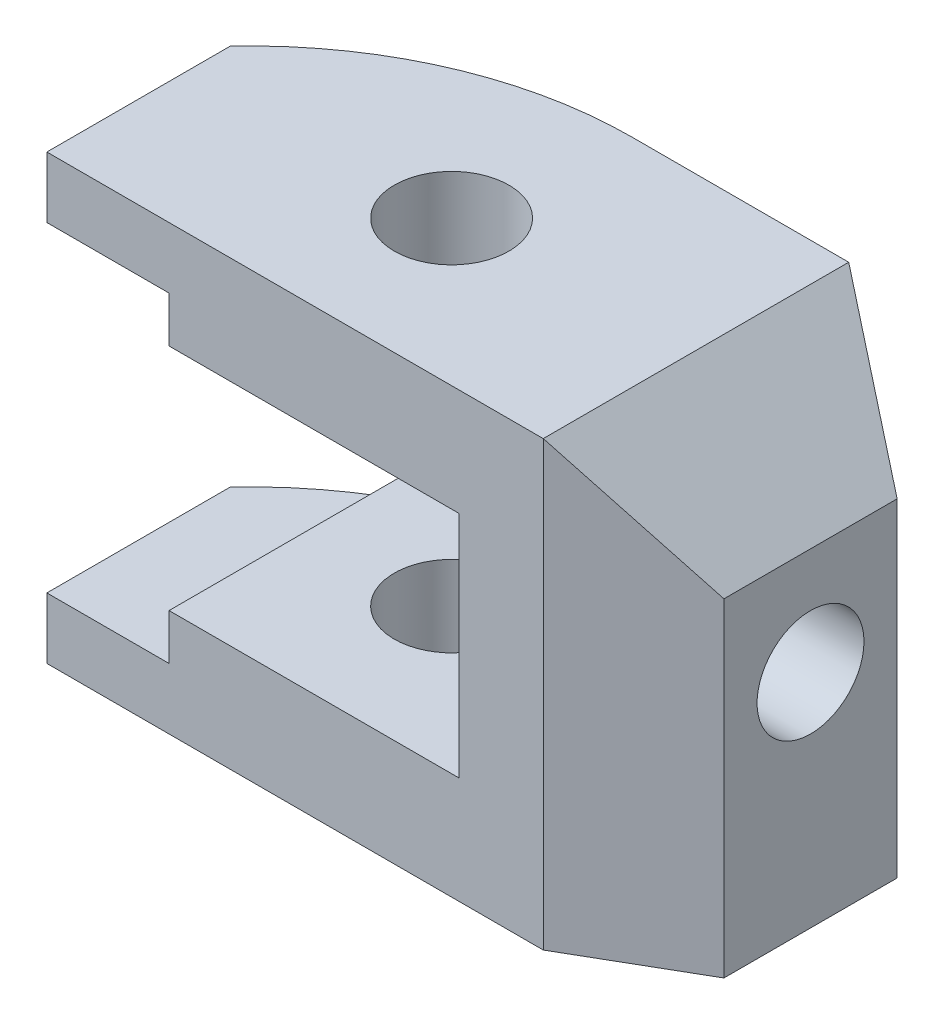
from build123d import *

# Parameters (mm, degrees)
SKETCH1_R           = 7.5
BOSS_EXTRUDE1_DEPTH = 58
CUT_EXTRUDE1_DEPTH  = 58
CUT_EXTRUDE2_DEPTH  = 58
CUT_EXTRUDE3_REACH  = 82
SKETCH4_R           = 7


with BuildPart() as part:
    # Sketch1 → Boss-Extrude1 (new body)
    with BuildSketch(Plane(origin=(0, 0, 0), x_dir=(1, 0, 0), z_dir=(0, 1, 0))):
        with BuildLine():
            Line((36.66060556, 40), (65, 40))
            Line((65, 40), (80, 31.339745962))
            Line((80, 31.339745962), (80, 8.660254038))
            Line((80, 8.660254038), (65, 0))
            Line((65, 0), (0, 0))
            Line((0, 0), (0, 24))
            ThreePointArc((0, 24), (16.66060556, 35.82575695), (36.66060556, 40))
        make_face()
        with Locations((34, 19)):
            Circle(SKETCH1_R, mode=Mode.SUBTRACT)
    extrude(amount=BOSS_EXTRUDE1_DEPTH)

    # Sketch2 → Cut-Extrude1 (cut)
    with BuildSketch(Plane(origin=(0, 0, -40), x_dir=(-1, 0, 0), z_dir=(0, 0, -1))):
        Polygon((0, 50), (-16, 50), (-16, 44), (-54, 44), (-54, 14), (-16, 14), (-16, 8), (0, 8), align=None)
    extrude(amount=-CUT_EXTRUDE1_DEPTH, mode=Mode.SUBTRACT)

    # Sketch3 → Cut-Extrude2 (cut)
    with BuildSketch(Plane(origin=(0, 0, -40), x_dir=(-1, 0, 0), z_dir=(0, 0, -1))):
        Polygon((-80, 58), (-80, 43), (-65, 58), align=None)
    extrude(amount=-CUT_EXTRUDE2_DEPTH, mode=Mode.SUBTRACT)

    # Sketch4 → Cut-Extrude3 (cut, up to next)
    with BuildSketch(Plane(origin=(80, 0, 0), x_dir=(0, 0, -1), z_dir=(1, 0, 0)), mode=Mode.PRIVATE) as cut_extrude3_sk1:
        with Locations((20, 29)):
            Circle(SKETCH4_R)
    cut_extrude3_tool1 = extrude(cut_extrude3_sk1.sketch, amount=-CUT_EXTRUDE3_REACH, mode=Mode.PRIVATE) & part.part
    add(cut_extrude3_tool1.solids().sort_by_distance((80, 29, -20))[0], mode=Mode.SUBTRACT)


solid = part.part
